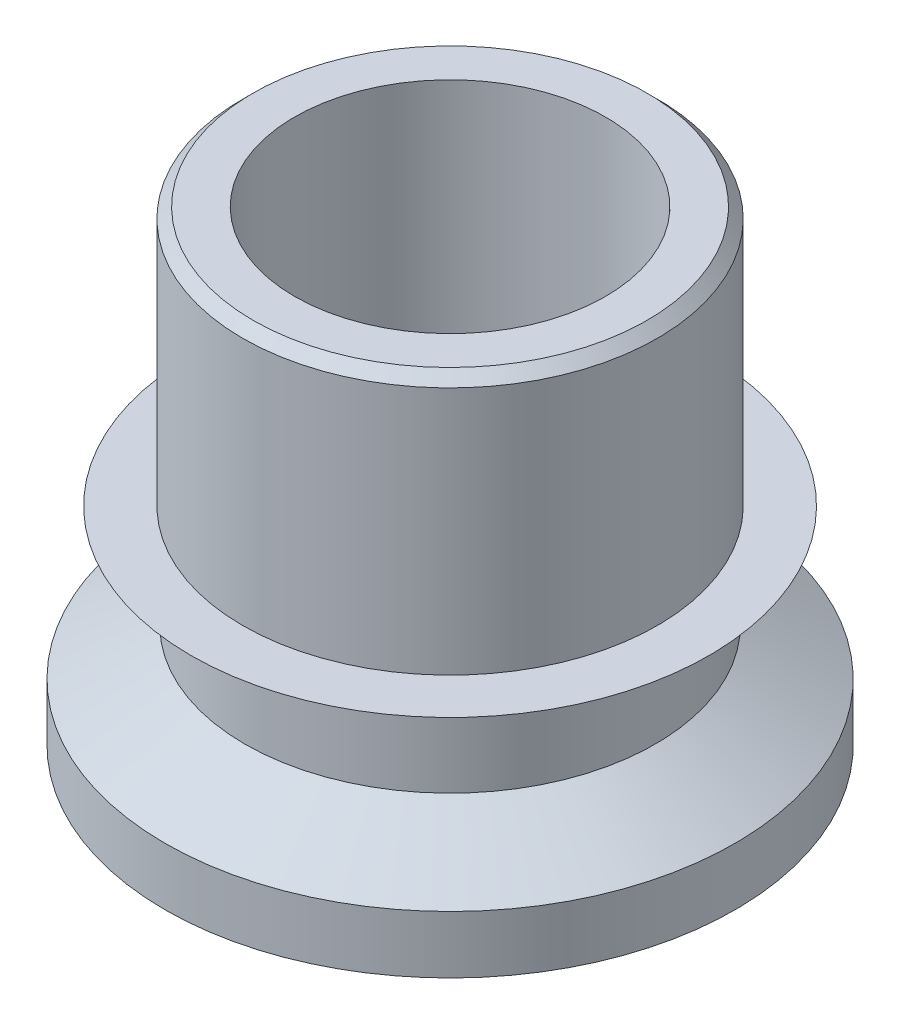
from build123d import *


with BuildPart() as part:
    # Sketch1 → Revolve1 (revolve)
    with BuildSketch(Plane.XY):
        Polygon((-3, 7), (-3.8, 7), (-4, 6.8), (-4, 2), (-5, 2), (-3.960769515, 1.4), (-3.960769515, 0), (-5.5, -0.888675135), (-5.5, -2), (-3, -2), align=None)
    revolve(axis=Axis((0, 0, 0), (0, -1, 0)))


solid = part.part
